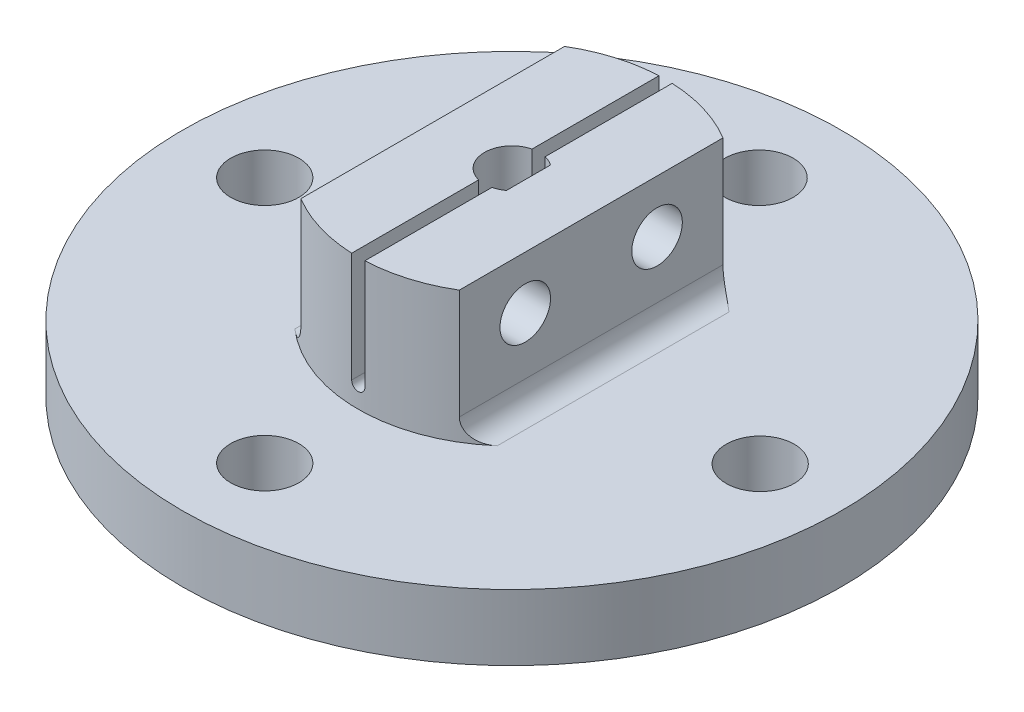
from build123d import *

# Parameters (mm, degrees)
SKETCH1_R               = 19.05
BOSS_EXTRUDE1_DEPTH     = 3.81
SKETCH2_R               = 8.89
BOSS_EXTRUDE2_DEPTH     = 7.62
CUT_EXTRUDE1_DEPTH      = 12.43
CUT_EXTRUDE2_DEPTH      = 20.05
CUT_EXTRUDE2_DEPTH_BACK = 20.05
CUT_EXTRUDE3_DEPTH      = 7.62
FILLET1_R               = 1.27
SKETCH6_R               = 1.4605
CUT_EXTRUDE4_DEPTH      = 24.62905012
SKETCH7_R               = 1.9685
CUT_EXTRUDE5_DEPTH      = 4.8100001


with BuildPart() as part:
    # Sketch1 → Boss-Extrude1 (new body)
    with BuildSketch(Plane(origin=(0, 0, 0), x_dir=(1, 0, 0), z_dir=(0, 1, 0))):
        Circle(SKETCH1_R)
    extrude(amount=BOSS_EXTRUDE1_DEPTH)

    # Sketch2 → Boss-Extrude2 (add)
    with BuildSketch(Plane(origin=(0, 3.81, 0), x_dir=(1, 0, 0), z_dir=(0, 1, 0))):
        Circle(SKETCH2_R)
    extrude(amount=BOSS_EXTRUDE2_DEPTH)

    # Sketch3 → Cut-Extrude1 (cut, through all)
    with BuildSketch(Plane(origin=(0, 11.43, 0), x_dir=(1, 0, 0), z_dir=(0, 1, 0))):
        with BuildLine():
            Line((0.9525, -1.27), (0.9525, 1.27))
            ThreePointArc((0.9525, 1.27), (-1.5875, 0), (0.9525, -1.27))
        make_face()
    extrude(amount=-CUT_EXTRUDE1_DEPTH, mode=Mode.SUBTRACT)

    # Sketch4 → Cut-Extrude2 (cut, two sides)
    with BuildSketch(Plane.XY) as cut_extrude2_sk:
        with BuildLine():
            Line((-0.381, 11.43), (-0.381, 5.08))
            ThreePointArc((-0.381, 5.08), (0, 4.699), (0.381, 5.08))
            Line((0.381, 5.08), (0.381, 11.43))
            Line((0.381, 11.43), (-0.381, 11.43))
        make_face()
    extrude(amount=CUT_EXTRUDE2_DEPTH, mode=Mode.SUBTRACT)
    extrude(cut_extrude2_sk.sketch, amount=-CUT_EXTRUDE2_DEPTH_BACK, mode=Mode.SUBTRACT)

    # Sketch5 → Cut-Extrude3 (cut)
    with BuildSketch(Plane(origin=(0, 11.43, 0), x_dir=(1, 0, 0), z_dir=(0, 1, 0))):
        with BuildLine():
            Line((4.57905012, 7.62), (4.57905012, -7.62))
            ThreePointArc((4.57905012, -7.62), (8.89, 0), (4.57905012, 7.62))
        make_face()
        with BuildLine():
            Line((-4.57905012, -7.62), (-4.57905012, 7.62))
            ThreePointArc((-4.57905012, 7.62), (-8.89, 0), (-4.57905012, -7.62))
        make_face()
    extrude(amount=-CUT_EXTRUDE3_DEPTH, mode=Mode.SUBTRACT)

    # Fillet1
    fillet1_edges = [part.edges().sort_by_distance(p)[0] for p in [
        (4.57905012, 3.81, 0),
        (-4.57905012, 3.81, 0),
    ]]
    fillet(fillet1_edges, radius=FILLET1_R)

    # Sketch6 → Cut-Extrude4 (cut, through all)
    with BuildSketch(Plane(origin=(4.57905012, 0, 0), x_dir=(0, 0, -1), z_dir=(1, 0, 0))):
        with Locations((-3.81, 8.382)):
            Circle(SKETCH6_R)
        with Locations((3.81, 8.382)):
            Circle(SKETCH6_R)
    extrude(amount=-CUT_EXTRUDE4_DEPTH, mode=Mode.SUBTRACT)

    # Sketch7 → Cut-Extrude5 (cut, through all)
    with BuildSketch(Plane(origin=(0, 3.81, 0), x_dir=(1, 0, 0), z_dir=(0, 1, 0))):
        with Locations((-14.2875, 0)):
            Circle(SKETCH7_R)
        with Locations((0, 14.2875)):
            Circle(SKETCH7_R)
        with Locations((14.351, 0)):
            Circle(SKETCH7_R)
        with Locations((0, -14.2875)):
            Circle(SKETCH7_R)
    extrude(amount=-CUT_EXTRUDE5_DEPTH, mode=Mode.SUBTRACT)


solid = part.part
